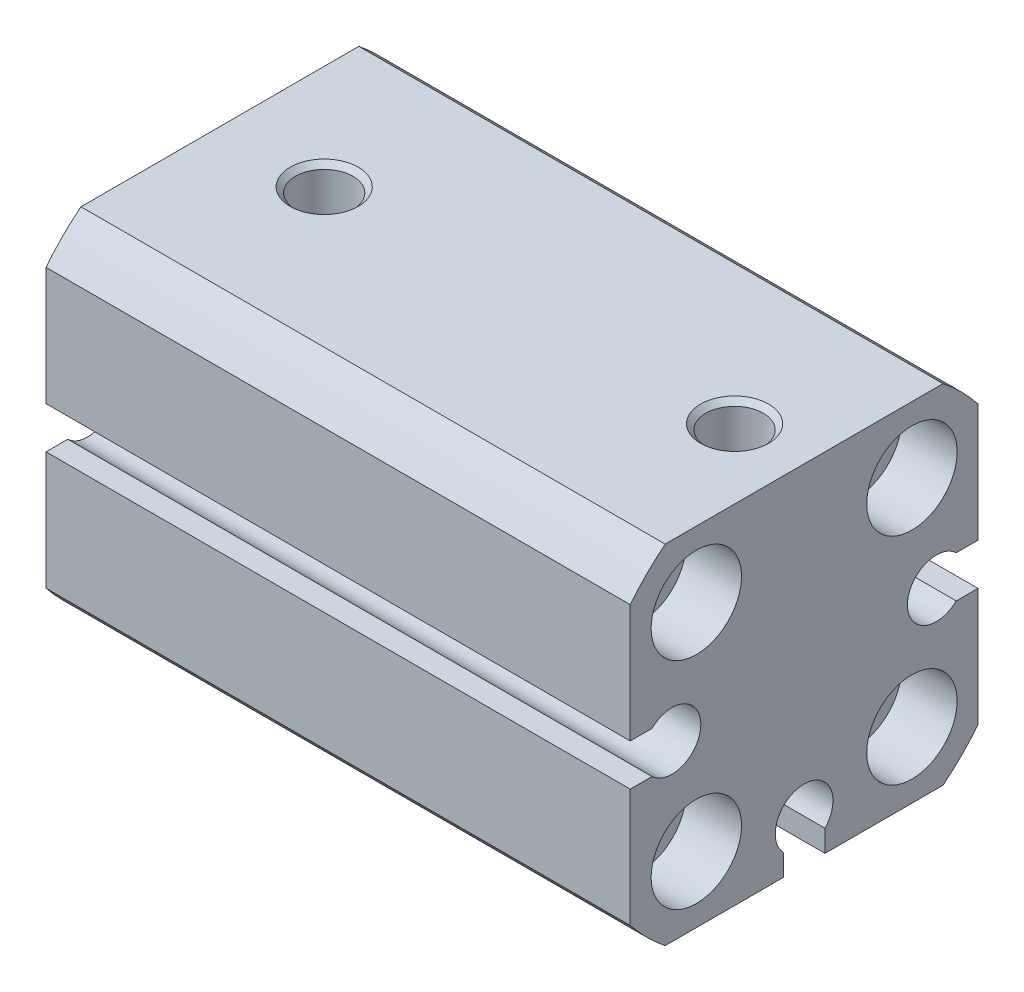
from build123d import *

# Parameters (mm, degrees)
BOSS_EXTRUDE1_DEPTH        = 42
CUT_EXTRUDE1_DEPTH         = 43
CUT_EXTRUDE2_DEPTH         = 43
CUT_EXTRUDE3_DEPTH         = 43
SKETCH10_W                 = 42
SKETCH10_H                 = 2.075
SKETCH11_W                 = 42
SKETCH11_H                 = 2.075
SKETCH12_W                 = 42
SKETCH12_H                 = 2.075
M3_5_CLEARANCE_HOLE1_D     = 4.134
M3_5_CLEARANCE_HOLE1_DEPTH = 5
M3_5_CLEARANCE_HOLE1_TIP   = 1.193383006
CHAMFER1_SIZE              = 0.379


with BuildPart() as part:
    # Sketch1 → Boss-Extrude1 (new body)
    with BuildSketch(Plane(origin=(42, 0, 0), x_dir=(0, 0, -1), z_dir=(1, 0, 0))):
        with BuildLine():
            Line((-12.5, 9.987492178), (-12.5, -9.987492178))
            ThreePointArc((-12.5, -9.987492178), (-11.313708499, -11.313708499), (-9.987492178, -12.5))
            Line((-9.987492178, -12.5), (9.987492178, -12.5))
            ThreePointArc((9.987492178, -12.5), (11.313708499, -11.313708499), (12.5, -9.987492178))
            Line((12.5, -9.987492178), (12.5, 9.987492178))
            ThreePointArc((12.5, 9.987492178), (11.313708499, 11.313708499), (9.987492178, 12.5))
            Line((9.987492178, 12.5), (-9.987492178, 12.5))
            ThreePointArc((-9.987492178, 12.5), (-11.313708499, 11.313708499), (-12.5, 9.987492178))
        make_face()
    extrude(amount=-BOSS_EXTRUDE1_DEPTH)

    # Sketch2 → Cut-Extrude1 (cut, through all)
    with BuildSketch(Plane.ZY):
        with BuildLine():
            Line((12.5, -1.5), (12.5, 1.5))
            Line((12.5, 1.5), (10.933745096, 1.5))
            ThreePointArc((10.933745096, 1.5), (11.575, 0), (10.933745096, -1.5))
            Line((10.933745096, -1.5), (12.5, -1.5))
        make_face()
    extrude(amount=-CUT_EXTRUDE1_DEPTH, mode=Mode.SUBTRACT)

    # Sketch3 → Cut-Extrude2 (cut, through all)
    with BuildSketch(Plane.ZY):
        with BuildLine():
            Line((-1.5, -12.5), (1.5, -12.5))
            Line((1.5, -12.5), (1.5, -10.933745096))
            ThreePointArc((1.5, -10.933745096), (0, -11.575), (-1.5, -10.933745096))
            Line((-1.5, -10.933745096), (-1.5, -12.5))
        make_face()
    extrude(amount=-CUT_EXTRUDE2_DEPTH, mode=Mode.SUBTRACT)

    # Sketch4 → Cut-Extrude3 (cut, through all)
    with BuildSketch(Plane.ZY):
        with BuildLine():
            Line((-12.5, 1.5), (-12.5, -1.5))
            Line((-12.5, -1.5), (-10.933745096, -1.5))
            ThreePointArc((-10.933745096, -1.5), (-11.575, 0), (-10.933745096, 1.5))
            Line((-10.933745096, 1.5), (-12.5, 1.5))
        make_face()
    extrude(amount=-CUT_EXTRUDE3_DEPTH, mode=Mode.SUBTRACT)

    # Sketch5 → Cut-Revolve1 (revolve, cut)
    with BuildSketch(Plane.XY):
        Polygon((0, 6.5), (0, 0), (36, 0), (36, 6), (11, 6), (11, 3), (1.2, 3), (1.2, 6.5), align=None)
    revolve(axis=Axis((0, 0, 0), (1, 0, 0)), mode=Mode.SUBTRACT)

    # Sketch6 → Cut-Revolve2 (revolve, cut)
    with BuildSketch(Plane(origin=(0, 0, -7.75), x_dir=(-1, 0, 0), z_dir=(0, 0, -1))):
        Polygon((-42, 11), (-42, 7.75), (0, 7.75), (0, 11), (-4, 11), (-4, 9.371), (-11, 9.371), (-11.074478185, 9.5), (-30.925521815, 9.5), (-31, 9.371), (-38, 9.371), (-38, 11), align=None)
    revolve(axis=Axis((42, 7.75, -7.75), (-1, 0, 0)), mode=Mode.SUBTRACT)

    # Sketch7 → Cut-Revolve3 (revolve, cut)
    with BuildSketch(Plane(origin=(0, 0, -7.75), x_dir=(-1, 0, 0), z_dir=(0, 0, -1))):
        Polygon((-42, -4.5), (-42, -7.75), (0, -7.75), (0, -4.5), (-4, -4.5), (-4, -6.129), (-11, -6.129), (-11.074478185, -6), (-30.925521815, -6), (-31, -6.129), (-38, -6.129), (-38, -4.5), align=None)
    revolve(axis=Axis((42, -7.75, -7.75), (-1, 0, 0)), mode=Mode.SUBTRACT)

    # Sketch8 → Cut-Revolve4 (revolve, cut)
    with BuildSketch(Plane(origin=(0, 0, 7.75), x_dir=(-1, 0, 0), z_dir=(0, 0, -1))):
        Polygon((-42, -4.5), (-42, -7.75), (0, -7.75), (0, -4.5), (-4, -4.5), (-4, -6.129), (-11, -6.129), (-11.074478185, -6), (-30.925521815, -6), (-31, -6.129), (-38, -6.129), (-38, -4.5), align=None)
    revolve(axis=Axis((42, -7.75, 7.75), (-1, 0, 0)), mode=Mode.SUBTRACT)

    # Sketch9 → Cut-Revolve5 (revolve, cut)
    with BuildSketch(Plane(origin=(0, 0, 7.75), x_dir=(-1, 0, 0), z_dir=(0, 0, -1))):
        Polygon((-42, 11), (-42, 7.75), (0, 7.75), (0, 11), (-4, 11), (-4, 9.371), (-11, 9.371), (-11.074478185, 9.5), (-30.925521815, 9.5), (-31, 9.371), (-38, 9.371), (-38, 11), align=None)
    revolve(axis=Axis((42, 7.75, 7.75), (-1, 0, 0)), mode=Mode.SUBTRACT)

    # Sketch10 → Cut-Revolve6 (revolve, cut)
    with BuildSketch(Plane.XY.offset(9.5)):
        with Locations((21, 1.0375)):
            Rectangle(SKETCH10_W, SKETCH10_H)
    revolve(axis=Axis((0, 0, 9.5), (1, 0, 0)), mode=Mode.SUBTRACT)

    # Sketch11 → Cut-Revolve7 (revolve, cut)
    with BuildSketch(Plane.XY):
        with Locations((21, -8.4625)):
            Rectangle(SKETCH11_W, SKETCH11_H)
    revolve(axis=Axis((0, -9.5, 0), (1, 0, 0)), mode=Mode.SUBTRACT)

    # Sketch12 → Cut-Revolve8 (revolve, cut)
    with BuildSketch(Plane.XY.offset(-9.5)):
        with Locations((21, 1.0375)):
            Rectangle(SKETCH12_W, SKETCH12_H)
    revolve(axis=Axis((0, 0, -9.5), (1, 0, 0)), mode=Mode.SUBTRACT)

    # M3.5 Clearance Hole1
    with Locations(Plane(origin=(0, 12.5, 0), x_dir=(1, 0, 0), z_dir=(0, 1, 0))):
        with Locations((7.5, 0), (37, 0)):
            Hole(M3_5_CLEARANCE_HOLE1_D / 2, depth=M3_5_CLEARANCE_HOLE1_DEPTH)
            with Locations((0, 0, -(M3_5_CLEARANCE_HOLE1_DEPTH + M3_5_CLEARANCE_HOLE1_TIP / 2))):  # 120° drill point
                Cone(0, M3_5_CLEARANCE_HOLE1_D / 2, M3_5_CLEARANCE_HOLE1_TIP, mode=Mode.SUBTRACT)

    # Chamfer1
    chamfer1_edges = [part.edges().sort_by_distance(p)[0] for p in [
        (4, -9.371, 7.75),
        (38, -9.371, 7.75),
        (4, 6.129, 7.75),
        (38, 6.129, 7.75),
        (39.067, 12.5, 0),
        (9.567, 12.5, 0),
        (4, 6.129, -7.75),
        (38, 6.129, -7.75),
        (4, -9.371, -7.75),
        (38, -9.371, -7.75),
    ]]
    chamfer(chamfer1_edges, length=CHAMFER1_SIZE)


solid = part.part
